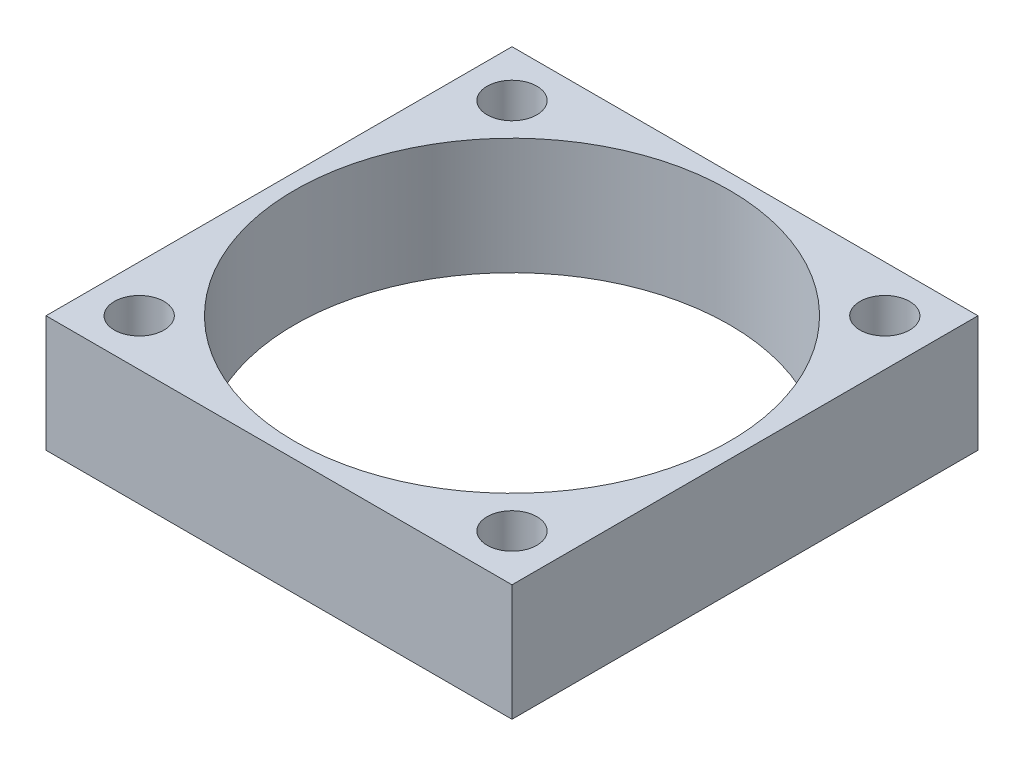
from build123d import *

# Parameters (mm, degrees)
SKETCH1_W           = 30
SKETCH1_H           = 30
SKETCH1_R           = 1.6
SKETCH1_R_2         = 14
BOSS_EXTRUDE1_DEPTH = 7.5


with BuildPart() as part:
    # Sketch1 → Boss-Extrude1 (new body)
    with BuildSketch(Plane(origin=(0, 0, 0), x_dir=(1, 0, 0), z_dir=(0, 1, 0))):
        with Locations((15, 15)):
            Rectangle(SKETCH1_W, SKETCH1_H)
        with Locations((3, 27)):
            Circle(SKETCH1_R, mode=Mode.SUBTRACT)
        with Locations((27, 27)):
            Circle(SKETCH1_R, mode=Mode.SUBTRACT)
        with Locations((27, 3)):
            Circle(SKETCH1_R, mode=Mode.SUBTRACT)
        with Locations((3, 3)):
            Circle(SKETCH1_R, mode=Mode.SUBTRACT)
        with Locations((15, 15)):
            Circle(SKETCH1_R_2, mode=Mode.SUBTRACT)
    extrude(amount=BOSS_EXTRUDE1_DEPTH)


solid = part.part
